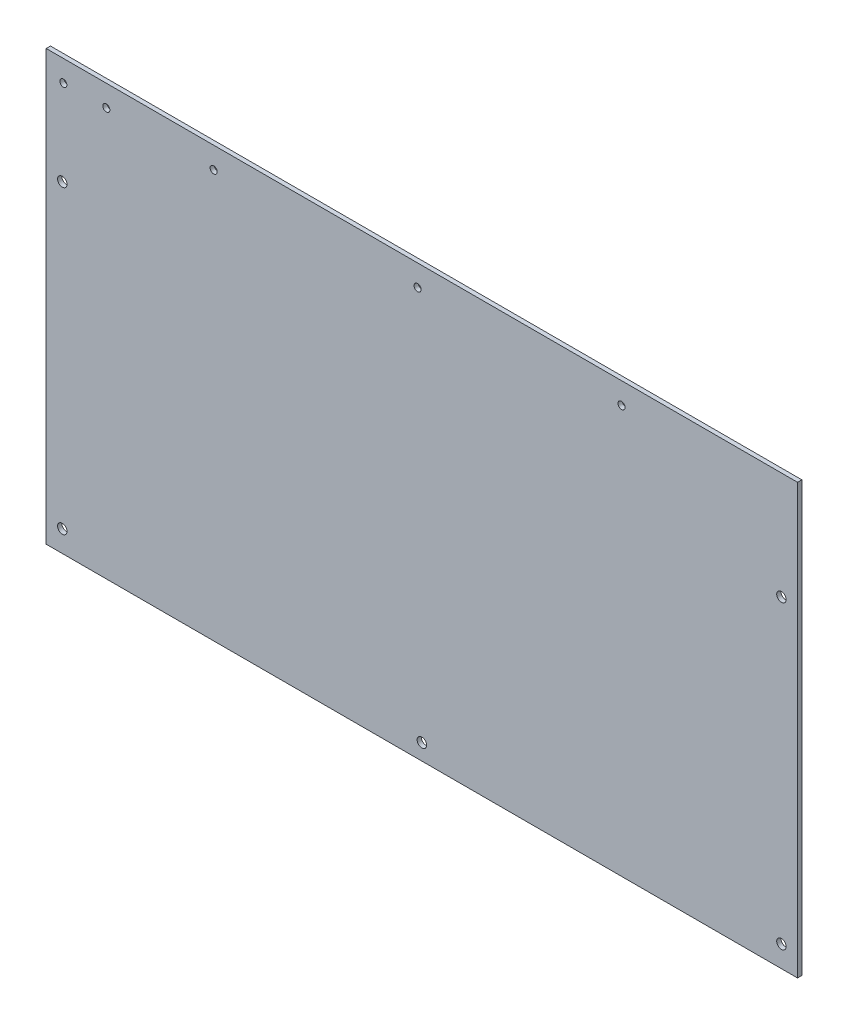
from build123d import *

# Parameters (mm, degrees)
SKETCH_1_W          = 350
SKETCH_1_H          = 200
EXTRUDE_1_DEPTH     = 2
SKETCH_3_R          = 2.2
CUT_EXTRUDE_2_DEPTH = 160
CUT_EXTRUDE_3_DEPTH = 160
SKETCH_9_R          = 1.092195423
SKETCH_9_R_2        = 1.081161574
SKETCH_9_R_3        = 1.093650915
CUT_EXTRUDE_6_DEPTH = 10
M4X0_7_3_D          = 3.3
SKETCH_12_R         = 1.094790711
SKETCH_12_R_2       = 0.646819846
CUT_EXTRUDE_7_DEPTH = 10
M4X0_7_4_D          = 3.3


with BuildPart() as part:
    # ｽｹｯﾁ1 → ﾎﾞｽ - 押し出し1 (new body)
    with BuildSketch(Plane.XY):
        Rectangle(SKETCH_1_W, SKETCH_1_H)
    extrude(amount=EXTRUDE_1_DEPTH)

    # ｽｹｯﾁ3 → ｶｯﾄ - 押し出し2 (cut)
    with BuildSketch(Plane.XY.offset(2)):
        with Locations((-167.5, 50)):
            Circle(SKETCH_3_R)
        with Locations((-167.5, -90)):
            Circle(SKETCH_3_R)
        with Locations((167.5, -90)):
            Circle(SKETCH_3_R)
        with Locations((167.5, 50)):
            Circle(SKETCH_3_R)
    extrude(amount=-CUT_EXTRUDE_2_DEPTH, mode=Mode.SUBTRACT)

    # ｽｹｯﾁ4 → ｶｯﾄ - 押し出し3 (cut)
    with BuildSketch(Plane.XY.offset(2)):
        with BuildLine():
            Line((0, -92.5), (-2.2, -92.5))
            ThreePointArc((-2.2, -92.5), (0, -94.7), (2.2, -92.5))
            Line((2.2, -92.5), (0, -92.5))
        make_face()
        with BuildLine():
            ThreePointArc((0, -90.3), (-1.555634919, -90.944365081), (-2.2, -92.5))
            Line((-2.2, -92.5), (0, -92.5))
            Line((0, -92.5), (0, -90.3))
        make_face()
        with BuildLine():
            Line((0, -90.3), (0, -92.5))
            Line((0, -92.5), (2.2, -92.5))
            ThreePointArc((2.2, -92.5), (1.555634919, -90.944365081), (0, -90.3))
        make_face()
    extrude(amount=-CUT_EXTRUDE_3_DEPTH, mode=Mode.SUBTRACT)

    # ｽｹｯﾁ9 → ｶｯﾄ - 押し出し6 (cut)
    with BuildSketch(Plane.XY.offset(2)):
        with Locations((-97, 90.026666535)):
            Circle(SKETCH_9_R)
        with Locations((-2, 90.026666535)):
            Circle(SKETCH_9_R_2)
        with Locations((93, 90.026666535)):
            Circle(SKETCH_9_R_3)
    extrude(amount=-CUT_EXTRUDE_6_DEPTH, mode=Mode.SUBTRACT)

    # M4x0.7 ねじ穴3 (through all)
    with Locations(Plane(origin=(93, 90.026666535, 2), x_dir=(1, 0, 0), z_dir=(0, 0, 1))):
        with Locations((0, 0), (-95, 0), (-190, 0)):
            Hole(M4X0_7_3_D / 2)

    # ｽｹｯﾁ12 → ｶｯﾄ - 押し出し7 (cut)
    with BuildSketch(Plane.XY.offset(2)):
        with Locations((-147, 90.026666535)):
            Circle(SKETCH_12_R)
        with Locations((-167, 90.026666535)):
            Circle(SKETCH_12_R_2)
    extrude(amount=-CUT_EXTRUDE_7_DEPTH, mode=Mode.SUBTRACT)

    # M4x0.7 ねじ穴4 (through all)
    with Locations(Plane(origin=(-147, 90.026666535, 2), x_dir=(1, 0, 0), z_dir=(0, 0, 1))):
        with Locations((0, 0), (-20, 0)):
            Hole(M4X0_7_4_D / 2)


solid = part.part
